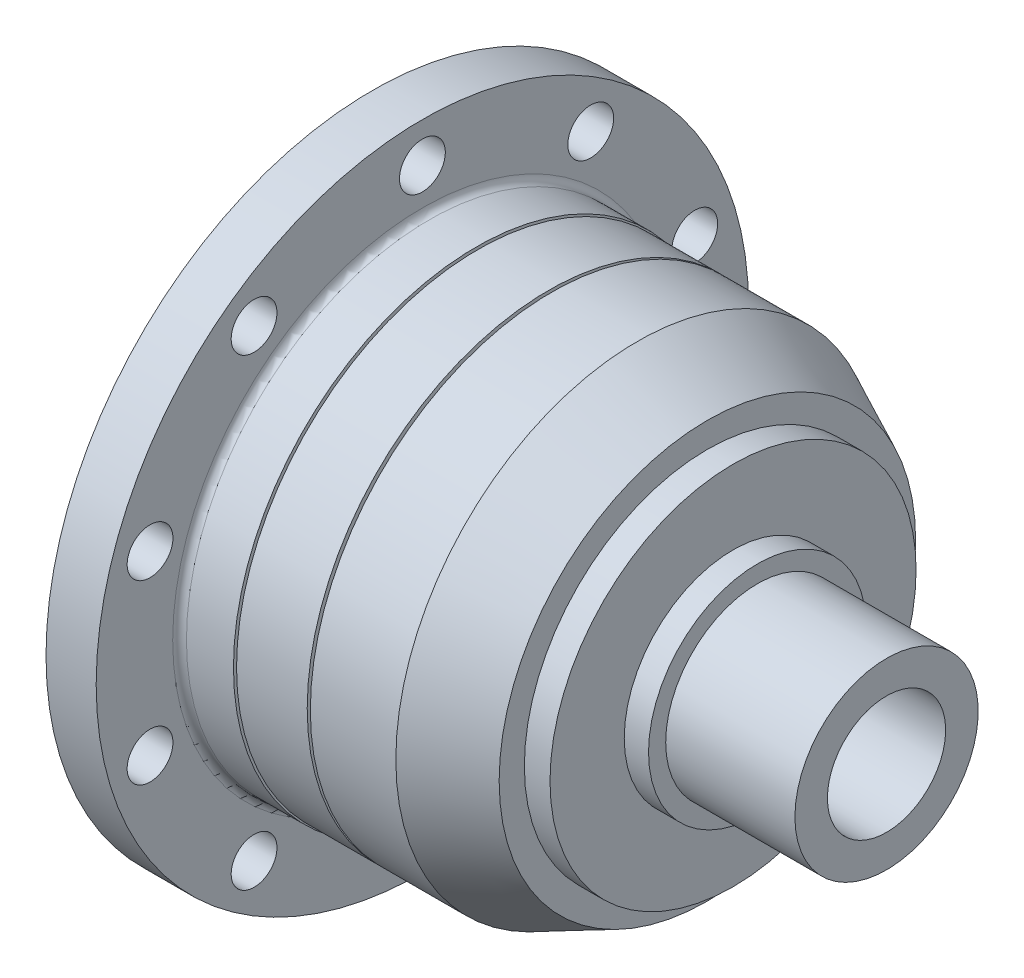
from build123d import *

# Parameters (mm, degrees)
SKETCH2_R      = 5
EXTRUDE1_DEPTH = 10.95
FILLET3_R      = 1.5


with BuildPart() as part:
    # Sketch1 → Revolve1 (revolve)
    with BuildSketch(Plane.XY):
        Polygon((0, 53), (0, 71.2), (-10.95, 71.2), (-10.95, 42.087444297), (-10.95, 24.85), (-12.95, 24.85), (-12.95, 20), (-34.5, 20), (-34.5, 12.9), (101.3, 12.9), (101.3, 20), (73.1, 20), (73.1, 23.75), (67.8, 23.75), (67.8, 39.95), (62.2, 39.95), (62.2, 45.45), (46.9, 52.7), (28.240404552, 52.7), (28.240404552, 51.349259098), (27.559120448, 51.349259098), (27.559120448, 52.7), (12.131909835, 52.7), (12.131909835, 50.122589957), (11.761037764, 50.122589957), (11.761037764, 53), align=None)
    revolve(axis=Axis((-78.843245127, 0, 0), (1, 0, 0)))

    # Sketch2 → Extrude1 (cut)
    with BuildSketch(Plane.ZY.offset(10.95)):
        with Locations((0, 62.5)):
            Circle(SKETCH2_R)
        with Locations((36.736578268, 50.563562148)):
            Circle(SKETCH2_R)
        with Locations((59.441032268, 19.313562148)):
            Circle(SKETCH2_R)
        with Locations((59.441032268, -19.313562148)):
            Circle(SKETCH2_R)
        with Locations((36.736578268, -50.563562148)):
            Circle(SKETCH2_R)
        with Locations((0, -62.5)):
            Circle(SKETCH2_R)
        with Locations((-36.736578268, -50.563562148)):
            Circle(SKETCH2_R)
        with Locations((-59.441032268, -19.313562148)):
            Circle(SKETCH2_R)
        with Locations((-59.441032268, 19.313562148)):
            Circle(SKETCH2_R)
        with Locations((-36.736578268, 50.563562148)):
            Circle(SKETCH2_R)
    extrude(amount=-EXTRUDE1_DEPTH, mode=Mode.SUBTRACT)

    # Fillet3
    fillet3_edges = [part.edges().sort_by_distance(p)[0] for p in [
        (0, -53, 0),
        (-10.95, -24.85, 0),
    ]]
    fillet(fillet3_edges, radius=FILLET3_R)


solid = part.part
